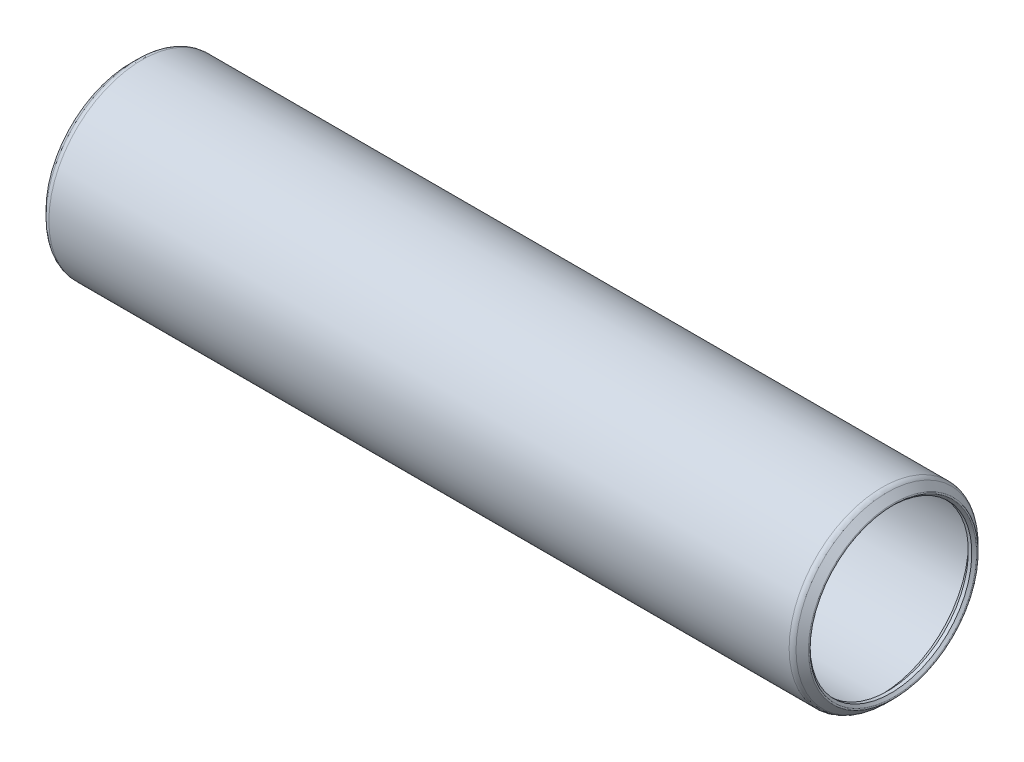
from build123d import *


with BuildPart() as part:
    # Sketch1 → Revolve1 (revolve)
    with BuildSketch(Plane.XY):
        with BuildLine():
            Line((-0.639512806, 9.167562806), (-0.381, 8.90905))
            Line((-0.381, 8.90905), (0, 8.90905))
            Line((0, 8.90905), (0.762, 9.67105))
            Line((0.762, 9.67105), (81.9531, 9.67105))
            Line((81.9531, 9.67105), (82.7151, 8.90905))
            Line((82.7151, 8.90905), (83.0961, 8.90905))
            Line((83.0961, 8.90905), (83.354612806, 9.167562806))
            ThreePointArc((83.354612806, 9.167562806), (83.391810245, 9.257365367), (83.354612806, 9.347167928))
            Line((83.354612806, 9.347167928), (82.669715367, 10.032065367))
            ThreePointArc((82.669715367, 10.032065367), (82.422504775, 10.197246204), (82.1309, 10.25525))
            Line((82.1309, 10.25525), (0.5842, 10.25525))
            ThreePointArc((0.5842, 10.25525), (0.292595225, 10.197246204), (0.045384633, 10.032065367))
            Line((0.045384633, 10.032065367), (-0.639512806, 9.347167928))
            ThreePointArc((-0.639512806, 9.347167928), (-0.676710245, 9.257365367), (-0.639512806, 9.167562806))
        make_face()
    revolve(axis=Axis((82.7151, 0, 0), (-1, 0, 0)))


solid = part.part
